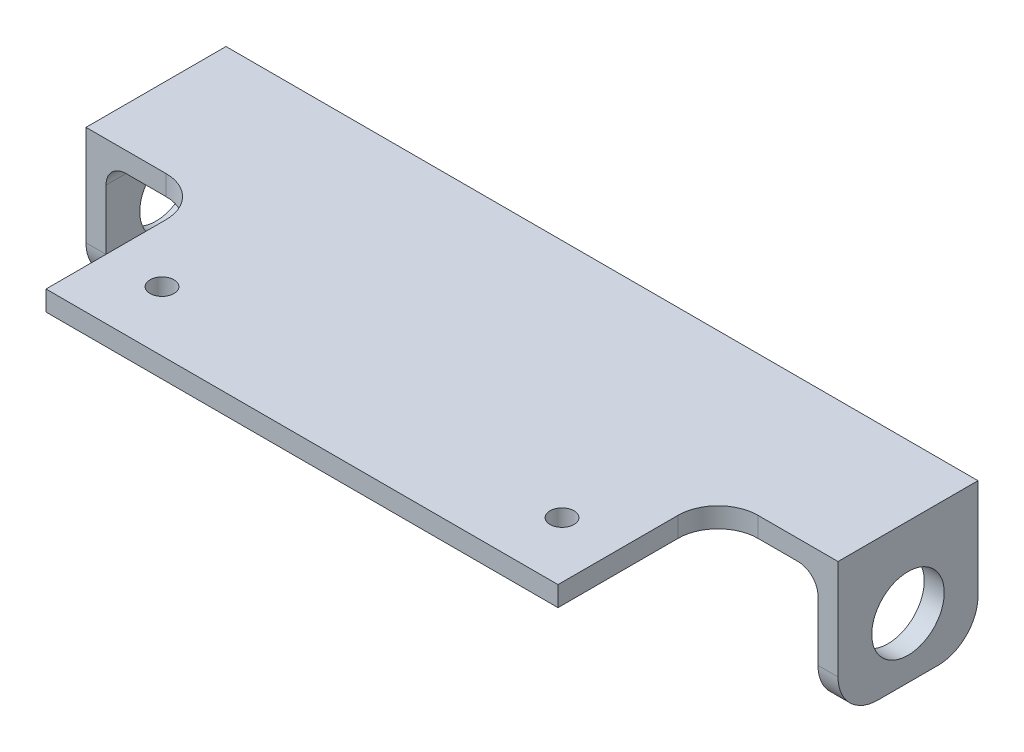
from build123d import *

# Parameters (mm, degrees)
EXTRUDE1_DEPTH                         = 25.4
EXTRUDE1_DEPTH_BACK                    = 50.8
SKETCH2_W                              = 119.38
SKETCH2_H                              = 22.225
EXTRUDE2_DEPTH                         = 3.175
SKETCH3_W                              = 3.175
SKETCH3_H                              = 22.225
EXTRUDE3_DEPTH                         = 19.05
TAP_DRILL_FOR_1_2_TAP1_D               = 11.50874
TAP_DRILL_FOR_1_2_TAP1_DEPTH           = 6.35
TAP_DRILL_FOR_1_2_TAP1_TIP             = 3.45757432
TAP_DRILL_FOR_1_2_TAP1_ON_FACE_2_D     = 11.50874
TAP_DRILL_FOR_1_2_TAP1_ON_FACE_2_DEPTH = 6.35
TAP_DRILL_FOR_1_2_TAP1_ON_FACE_2_TIP   = 3.45757432
F_8_CLEARANCE_HOLE1_D                  = 4.4958
F_8_CLEARANCE_HOLE1_DEPTH              = 6.35
F_8_CLEARANCE_HOLE1_TIP                = 1.350674586
F_8_CLEARANCE_HOLE1_ON_FACE_2_D        = 4.4958
F_8_CLEARANCE_HOLE1_ON_FACE_2_DEPTH    = 6.35
F_8_CLEARANCE_HOLE1_ON_FACE_2_TIP      = 1.350674586
FILLET1_R                              = 6.35
FILLET3_R                              = 3.175
SKETCH7_W                              = 81.28
SKETCH7_H                              = 3.175
EXTRUDE4_DEPTH                         = 25.4
FILLET4_R                              = 6.35
F_6_CLEARANCE_HOLE1_D                  = 3.7973
F_6_CLEARANCE_HOLE1_DEPTH              = 9.652
F_6_CLEARANCE_HOLE1_TIP                = 1.140824014
SKETCH8_W                              = 66.338719692
SKETCH8_H                              = 61.141500313
CUT_EXTRUDE1_DEPTH                     = 57.15


with BuildPart() as part:
    # Sketch1 → Extrude1 (new body, two sides)
    with BuildSketch(Plane(origin=(0, 0, 0), x_dir=(1, 0, 0), z_dir=(0, 1, 0))) as extrude1_sk:
        with BuildLine():
            Line((15.24, -11.1125), (-15.24, -11.1125))
            ThreePointArc((-15.24, -11.1125), (-19.730128061, -9.252628061), (-21.59, -4.7625))
            Line((-21.59, -4.7625), (-21.59, 4.7625))
            ThreePointArc((-21.59, 4.7625), (-19.730128061, 9.252628061), (-15.24, 11.1125))
            Line((-15.24, 11.1125), (15.24, 11.1125))
            ThreePointArc((15.24, 11.1125), (19.730128061, 9.252628061), (21.59, 4.7625))
            Line((21.59, 4.7625), (21.59, -4.7625))
            ThreePointArc((21.59, -4.7625), (19.730128061, -9.252628061), (15.24, -11.1125))
        make_face()
        with BuildLine():
            Line((-15.24, -7.9375), (-5.715, -7.9375))
            ThreePointArc((-5.715, -7.9375), (-3.46993597, -7.00756403), (-2.54, -4.7625))
            Line((-2.54, -4.7625), (-2.54, 4.7625))
            ThreePointArc((-2.54, 4.7625), (-3.46993597, 7.00756403), (-5.715, 7.9375))
            Line((-5.715, 7.9375), (-15.24, 7.9375))
            ThreePointArc((-15.24, 7.9375), (-17.48506403, 7.00756403), (-18.415, 4.7625))
            Line((-18.415, 4.7625), (-18.415, -4.7625))
            ThreePointArc((-18.415, -4.7625), (-17.48506403, -7.00756403), (-15.24, -7.9375))
        make_face(mode=Mode.SUBTRACT)
        with BuildLine():
            Line((15.24, 7.9375), (5.715, 7.9375))
            ThreePointArc((5.715, 7.9375), (3.46993597, 7.00756403), (2.54, 4.7625))
            Line((2.54, 4.7625), (2.54, -4.7625))
            ThreePointArc((2.54, -4.7625), (3.46993597, -7.00756403), (5.715, -7.9375))
            Line((5.715, -7.9375), (15.24, -7.9375))
            ThreePointArc((15.24, -7.9375), (17.48506403, -7.00756403), (18.415, -4.7625))
            Line((18.415, -4.7625), (18.415, 4.7625))
            ThreePointArc((18.415, 4.7625), (17.48506403, 7.00756403), (15.24, 7.9375))
        make_face(mode=Mode.SUBTRACT)
    extrude(amount=EXTRUDE1_DEPTH)
    extrude(extrude1_sk.sketch, amount=-EXTRUDE1_DEPTH_BACK)

    # Sketch2 → Extrude2 (add)
    with BuildSketch(Plane(origin=(0, 25.4, 0), x_dir=(-1, 0, 0), z_dir=(0, 1, 0))):
        Rectangle(SKETCH2_W, SKETCH2_H)
    extrude(amount=EXTRUDE2_DEPTH)

    # Sketch3 → Extrude3 (add)
    with BuildSketch(Plane.XZ.offset(-25.4)):
        with Locations((-58.1025, 0)):
            Rectangle(SKETCH3_W, SKETCH3_H)
        with Locations((58.1025, 0)):
            Rectangle(SKETCH3_W, SKETCH3_H)
    extrude(amount=EXTRUDE3_DEPTH)

    # Tap Drill for 1/2 Tap1
    with Locations(Plane(origin=(-59.69, 15.875, 0), x_dir=(0, 0, -1), z_dir=(-1, 0, 0))):
        with Locations((0, 0)):
            Hole(TAP_DRILL_FOR_1_2_TAP1_D / 2, depth=TAP_DRILL_FOR_1_2_TAP1_DEPTH)
            with Locations((0, 0, -(TAP_DRILL_FOR_1_2_TAP1_DEPTH + TAP_DRILL_FOR_1_2_TAP1_TIP / 2))):  # 118° drill point
                Cone(0, TAP_DRILL_FOR_1_2_TAP1_D / 2, TAP_DRILL_FOR_1_2_TAP1_TIP, mode=Mode.SUBTRACT)

    # Tap Drill for 1/2 Tap1 on face 2
    with Locations(Plane(origin=(59.69, 15.875, 0), x_dir=(0, 0, 1), z_dir=(1, 0, 0))):
        with Locations((0, 0)):
            Hole(TAP_DRILL_FOR_1_2_TAP1_ON_FACE_2_D / 2, depth=TAP_DRILL_FOR_1_2_TAP1_ON_FACE_2_DEPTH)
            with Locations((0, 0, -(TAP_DRILL_FOR_1_2_TAP1_ON_FACE_2_DEPTH + TAP_DRILL_FOR_1_2_TAP1_ON_FACE_2_TIP / 2))):  # 118° drill point
                Cone(0, TAP_DRILL_FOR_1_2_TAP1_ON_FACE_2_D / 2, TAP_DRILL_FOR_1_2_TAP1_ON_FACE_2_TIP, mode=Mode.SUBTRACT)

    # #8 Clearance Hole1
    with Locations(Plane(origin=(-21.59, 15.875, 0), x_dir=(0, 0, -1), z_dir=(-1, 0, 0))):
        with Locations((0, 0)):
            Hole(F_8_CLEARANCE_HOLE1_D / 2, depth=F_8_CLEARANCE_HOLE1_DEPTH)
            with Locations((0, 0, -(F_8_CLEARANCE_HOLE1_DEPTH + F_8_CLEARANCE_HOLE1_TIP / 2))):  # 118° drill point
                Cone(0, F_8_CLEARANCE_HOLE1_D / 2, F_8_CLEARANCE_HOLE1_TIP, mode=Mode.SUBTRACT)

    # #8 Clearance Hole1 on face 2
    with Locations(Plane(origin=(21.59, 15.875, 0), x_dir=(0, 0, 1), z_dir=(1, 0, 0))):
        with Locations((0, 0)):
            Hole(F_8_CLEARANCE_HOLE1_ON_FACE_2_D / 2, depth=F_8_CLEARANCE_HOLE1_ON_FACE_2_DEPTH)
            with Locations((0, 0, -(F_8_CLEARANCE_HOLE1_ON_FACE_2_DEPTH + F_8_CLEARANCE_HOLE1_ON_FACE_2_TIP / 2))):  # 118° drill point
                Cone(0, F_8_CLEARANCE_HOLE1_ON_FACE_2_D / 2, F_8_CLEARANCE_HOLE1_ON_FACE_2_TIP, mode=Mode.SUBTRACT)

    # Fillet1
    fillet1_edges = [part.edges().sort_by_distance(p)[0] for p in [
        (-58.1025, 6.35, -11.1125),
        (-58.1025, 6.35, 11.1125),
        (58.1025, 6.35, 11.1125),
        (58.1025, 6.35, -11.1125),
    ]]
    fillet(fillet1_edges, radius=FILLET1_R)

    # Fillet3
    fillet3_edges = [part.edges().sort_by_distance(p)[0] for p in [
        (-56.515, 25.4, 0),
        (56.515, 25.4, 0),
    ]]
    fillet(fillet3_edges, radius=FILLET3_R)

    # Sketch7 → Extrude4 (add)
    with BuildSketch(Plane.XY.offset(11.1125)):
        with Locations((0, 26.9875)):
            Rectangle(SKETCH7_W, SKETCH7_H)
    extrude(amount=EXTRUDE4_DEPTH)

    # Fillet4
    fillet4_edges = [part.edges().sort_by_distance(p)[0] for p in [
        (-40.64, 26.9875, 11.1125),
        (40.64, 26.9875, 11.1125),
    ]]
    fillet(fillet4_edges, radius=FILLET4_R)

    # #6 Clearance Hole1
    with Locations(Plane(origin=(31.75, 28.575, 26.9875), x_dir=(0, 0, 1), z_dir=(0, 1, 0))):
        with Locations((0, 0), (0, -63.5)):
            Hole(F_6_CLEARANCE_HOLE1_D / 2, depth=F_6_CLEARANCE_HOLE1_DEPTH)
            with Locations((0, 0, -(F_6_CLEARANCE_HOLE1_DEPTH + F_6_CLEARANCE_HOLE1_TIP / 2))):  # 118° drill point
                Cone(0, F_6_CLEARANCE_HOLE1_D / 2, F_6_CLEARANCE_HOLE1_TIP, mode=Mode.SUBTRACT)

    # Sketch8 → Cut-Extrude1 (cut)
    with BuildSketch(Plane.XZ.offset(50.8)):
        with Locations((-0.031295894, -3.796156427)):
            Rectangle(SKETCH8_W, SKETCH8_H)
    extrude(amount=-CUT_EXTRUDE1_DEPTH, mode=Mode.SUBTRACT)


solid = part.part
